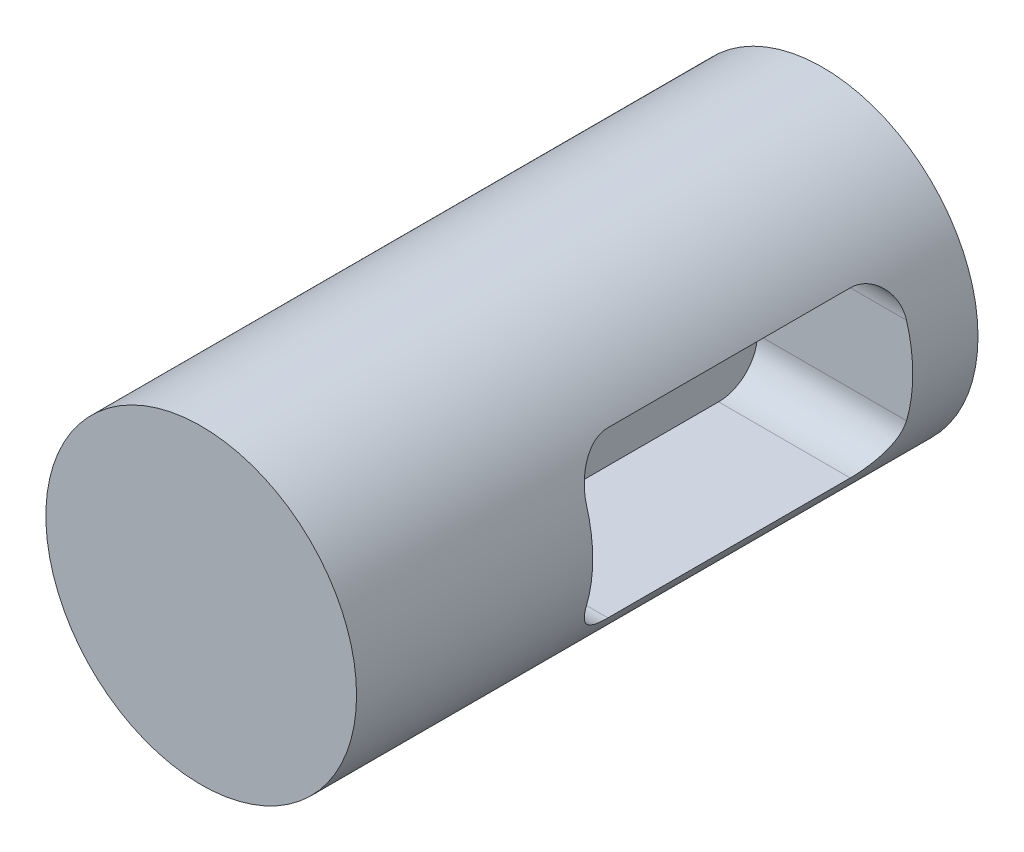
from build123d import *

# Parameters (mm, degrees)
SKETCH1_R           = 6.35
BOSS_EXTRUDE1_DEPTH = 25.4
SKETCH4_W           = 13.081
SKETCH4_H           = 6.731
CUT_EXTRUDE1_DEPTH  = 6.35
FILLET1_R           = 1.5875


with BuildPart() as part:
    # Sketch1 → Boss-Extrude1 (new body)
    with BuildSketch(Plane.XY):
        Circle(SKETCH1_R)
    extrude(amount=BOSS_EXTRUDE1_DEPTH)

    # Sketch4 → Cut-Extrude1 (cut)
    with BuildSketch(Plane(origin=(6.35, 0, 0), x_dir=(0, 0, -1), z_dir=(1, 0, 0))):
        with Locations((-9.2075, 0)):
            Rectangle(SKETCH4_W, SKETCH4_H)
    extrude(amount=-CUT_EXTRUDE1_DEPTH, mode=Mode.SUBTRACT)

    # Fillet1
    fillet1_edges = [part.edges().sort_by_distance(p)[0] for p in [
        (2.692392512, -3.3655, 15.748),
        (2.692392512, 3.3655, 15.748),
        (2.692392512, 3.3655, 2.667),
        (2.692392512, -3.3655, 2.667),
    ]]
    fillet(fillet1_edges, radius=FILLET1_R)


solid = part.part
